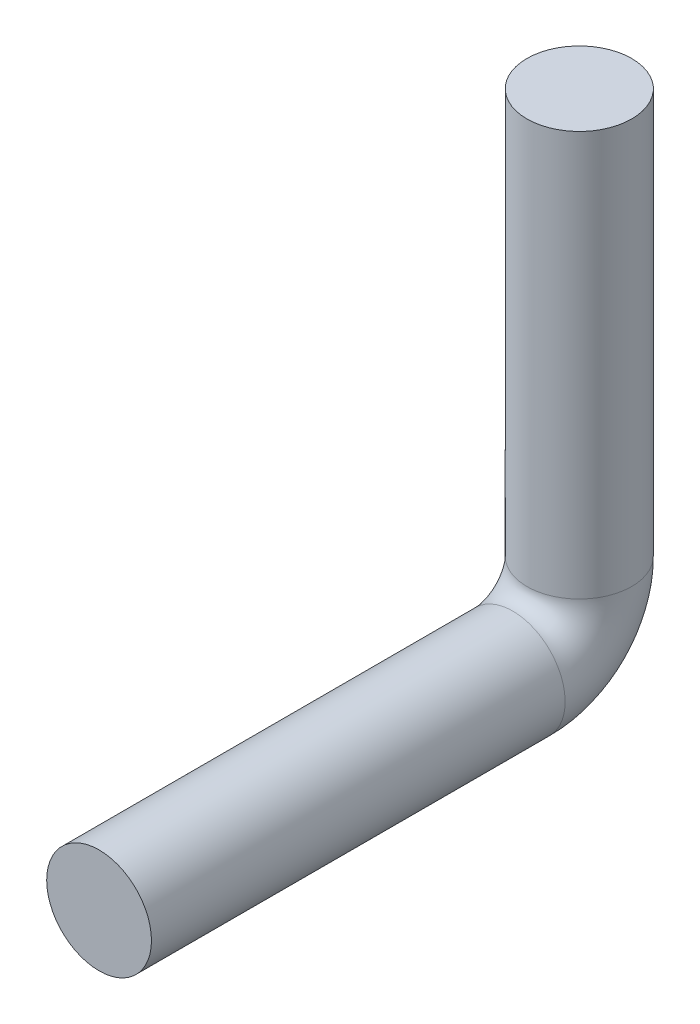
from build123d import *

# Parameters (mm, degrees)
SKETCH1_R = 30


with BuildPart() as part:
    # Sweep1: sweep along a path in Sketch2
    with BuildLine(Plane(origin=(0, 0, 0), x_dir=(0, 0, -1), z_dir=(1, 0, 0))) as sweep1_path:
        Line((0, 0), (0, -231.9))
        ThreePointArc((0, -231.9), (-11.159231637, -258.840768363), (-38.1, -270))
        Line((-38.1, -270), (-275, -270))
    # Sketch1 → Sweep1 (sweep)
    with BuildSketch(Plane(origin=(0, 0, 0), x_dir=(1, 0, 0), z_dir=(0, 1, 0))):
        Circle(SKETCH1_R)
    sweep(path=sweep1_path.line)


solid = part.part
